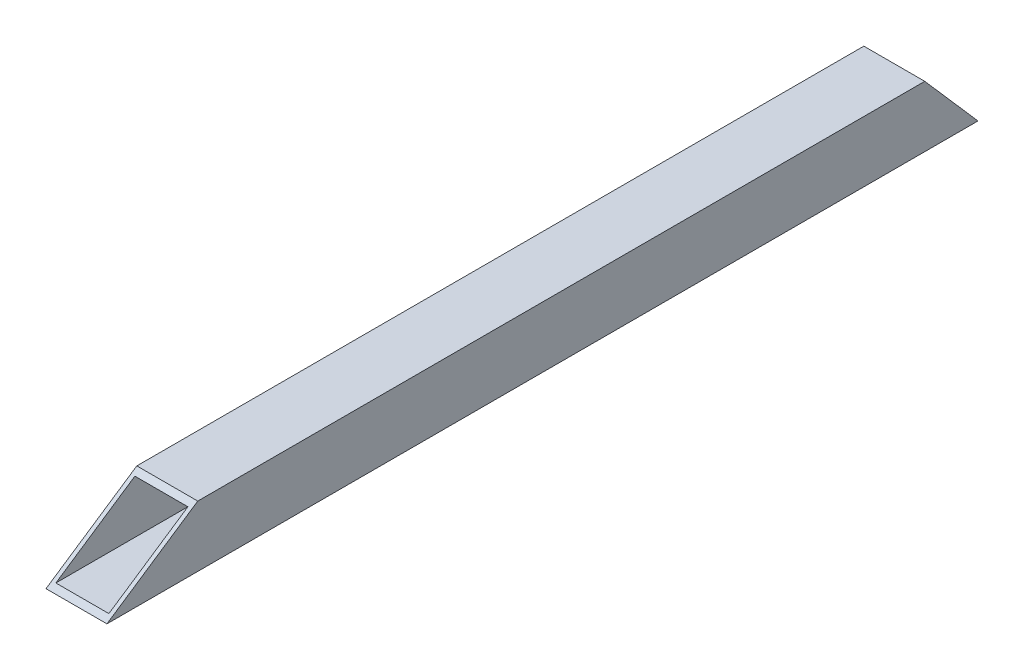
from build123d import *

# Parameters (mm, degrees)
SKETCH1_W           = 25.4
SKETCH1_H           = 25.4
SKETCH1_W_2         = 22.098
SKETCH1_H_2         = 22.098
BOSS_EXTRUDE1_DEPTH = 365.442999
SKETCH5_W           = 25.4
SKETCH5_H           = 25.4
CUT_EXTRUDE2_DEPTH  = 244.121497904
CUT_EXTRUDE3_DEPTH  = 26.4


with BuildPart() as part:
    # Sketch1 → Boss-Extrude1 (new body)
    with BuildSketch(Plane.XY):
        Rectangle(SKETCH1_W, SKETCH1_H)
        Rectangle(SKETCH1_W_2, SKETCH1_H_2, mode=Mode.SUBTRACT)
    extrude(amount=BOSS_EXTRUDE1_DEPTH)

    # Sketch5 → Cut-Extrude2 (cut, through all)
    with BuildSketch(Plane(origin=(0, 132.21706056, 169.900698991), x_dir=(-1, 0, 0), z_dir=(0, 0.557172611, -0.830396701))):
        Rectangle(SKETCH5_W, SKETCH5_H)
    extrude(amount=-CUT_EXTRUDE2_DEPTH, mode=Mode.SUBTRACT)

    # Sketch6 → Cut-Extrude3 (cut, through all)
    with BuildSketch(Plane.ZY.offset(12.7)):
        Polygon((0, -12.7), (25.987122875, 17.048162291), (0, 20.823213659), align=None)
    extrude(amount=-CUT_EXTRUDE3_DEPTH, mode=Mode.SUBTRACT)


solid = part.part
